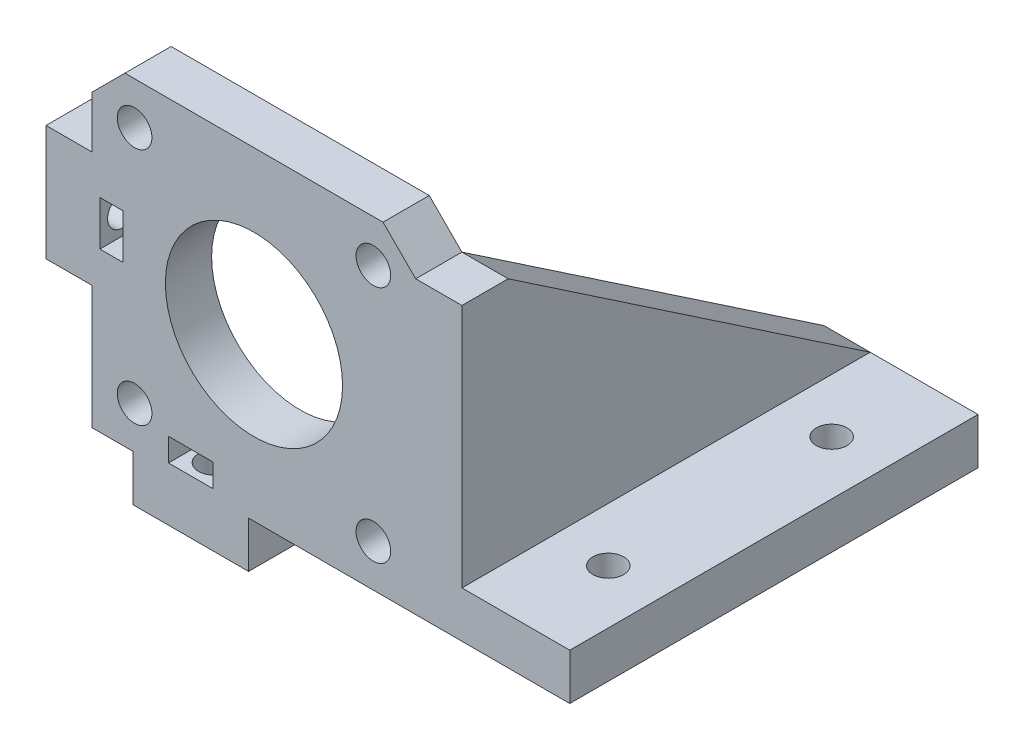
from build123d import *

# Parameters (mm, degrees)
ESQUISSE1_R             = 11.5
ESQUISSE1_R_2           = 2.25
ESQUISSE1_W             = 3
ESQUISSE1_H             = 5.8
ESQUISSE1_W_2           = 5.8
ESQUISSE1_H_2           = 3
BOSS_EXTRU_2_DEPTH      = 6
BOSS_EXTRU_4_DEPTH      = 6
ESQUISSE11_W            = 14
ESQUISSE11_H            = 53
ESQUISSE11_R            = 2
BOSS_EXTRU_5_DEPTH      = 6
ESQUISSE13_R            = 2
ENL_V_MAT_EXTRU_1_DEPTH = 14
ESQUISSE14_R            = 2
ENL_V_MAT_EXTRU_2_DEPTH = 14


with BuildPart() as part:
    # Esquisse1 → Boss.-Extru.2 (new body)
    with BuildSketch(Plane.XY):
        Polygon((0, 0), (0, 16), (-6, 16), (-6, 31), (0, 31), (0, 37.757359313), (4.242640687, 42), (37.757359313, 42), (42, 37.757359313), (42, 0), (20.3, 0), (20.3, -6), (5.3, -6), (5.3, 0), align=None)
        with Locations((21, 21)):
            Circle(ESQUISSE1_R, mode=Mode.SUBTRACT)
        with Locations((5.5, 36.5)):
            Circle(ESQUISSE1_R_2, mode=Mode.SUBTRACT)
        with Locations((36.5, 36.5)):
            Circle(ESQUISSE1_R_2, mode=Mode.SUBTRACT)
        with Locations((5.5, 5.5)):
            Circle(ESQUISSE1_R_2, mode=Mode.SUBTRACT)
        with Locations((36.5, 5.5)):
            Circle(ESQUISSE1_R_2, mode=Mode.SUBTRACT)
        with Locations((2.5, 23.5)):
            Rectangle(ESQUISSE1_W, ESQUISSE1_H, mode=Mode.SUBTRACT)
        with Locations((12.8, 2.5)):
            Rectangle(ESQUISSE1_W_2, ESQUISSE1_H_2, mode=Mode.SUBTRACT)
    extrude(amount=BOSS_EXTRU_2_DEPTH)

    # Esquisse9 → Boss.-Extru.4 (add)
    with BuildSketch(Plane(origin=(42, 0, 0), x_dir=(0, 0, -1), z_dir=(1, 0, 0))):
        Polygon((-6, 0), (47, 0), (47, 6), (0, 37.757359313), (-6, 37.757359313), align=None)
    extrude(amount=BOSS_EXTRU_4_DEPTH)

    # Esquisse11 → Boss.-Extru.5 (add)
    with BuildSketch(Plane.XZ):
        with Locations((55, -20.5)):
            Rectangle(ESQUISSE11_W, ESQUISSE11_H)
        with Locations((55, -35)):
            Circle(ESQUISSE11_R, mode=Mode.SUBTRACT)
        with Locations((55, -6)):
            Circle(ESQUISSE11_R, mode=Mode.SUBTRACT)
    extrude(amount=-BOSS_EXTRU_5_DEPTH)

    # Esquisse13 → Enlèv. mat.-Extru.1 (cut)
    with BuildSketch(Plane.ZY.offset(6)):
        with Locations((3, 23.5)):
            Circle(ESQUISSE13_R)
    extrude(amount=-ENL_V_MAT_EXTRU_1_DEPTH, mode=Mode.SUBTRACT)

    # Esquisse14 → Enlèv. mat.-Extru.2 (cut)
    with BuildSketch(Plane.XZ.offset(6)):
        with Locations((12.8, 3)):
            Circle(ESQUISSE14_R)
    extrude(amount=-ENL_V_MAT_EXTRU_2_DEPTH, mode=Mode.SUBTRACT)


solid = part.part
